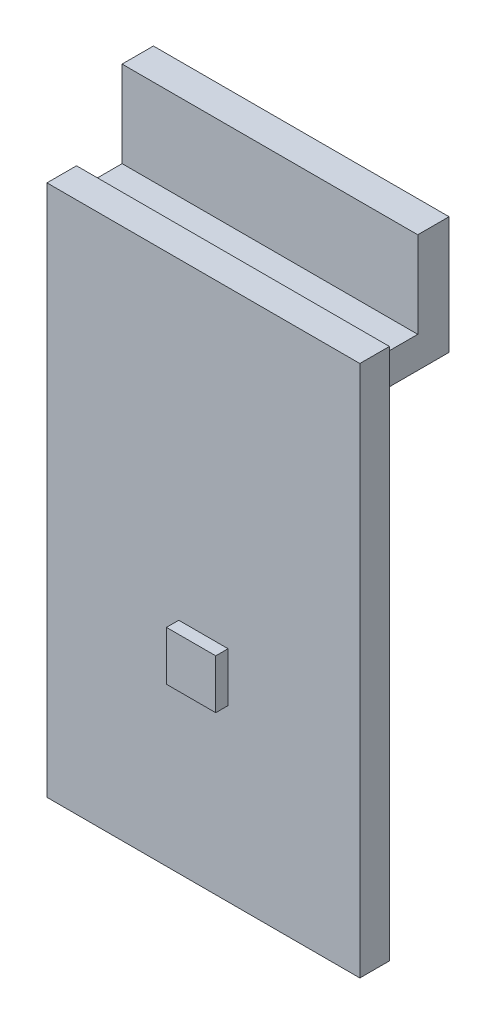
from build123d import *

# Parameters (mm, degrees)
ESBO_O1_W                = 12.7
ESBO_O1_H                = 21.6
RESSALTO_EXTRUS_O1_DEPTH = 1.2
ESBO_O2_W                = 2
ESBO_O2_H                = 2
RESSALTO_EXTRUS_O2_DEPTH = 0.5
RESSALTO_EXTRUS_O3_DEPTH = 6


with BuildPart() as part:
    # Esboço1 → Ressalto-extrusão1 (new body)
    with BuildSketch(Plane.XY):
        Rectangle(ESBO_O1_W, ESBO_O1_H)
    extrude(amount=RESSALTO_EXTRUS_O1_DEPTH)

    # Esboço2 → Ressalto-extrusão2 (add)
    with BuildSketch(Plane.XY.offset(1.2)):
        with Locations((0, -2.9)):
            Rectangle(ESBO_O2_W, ESBO_O2_H)
    extrude(amount=RESSALTO_EXTRUS_O2_DEPTH)

    # Esboço3 → Ressalto-extrusão3 (add, symmetric)
    with BuildSketch(Plane(origin=(0, 0, 0), x_dir=(0, 0, -1), z_dir=(1, 0, 0))):
        Polygon((0, 10.3), (1.5, 10.3), (1.5, 13.8), (2.77, 13.8), (2.77, 9.03), (0, 9.03), align=None)
    extrude(amount=RESSALTO_EXTRUS_O3_DEPTH, both=True)


solid = part.part
